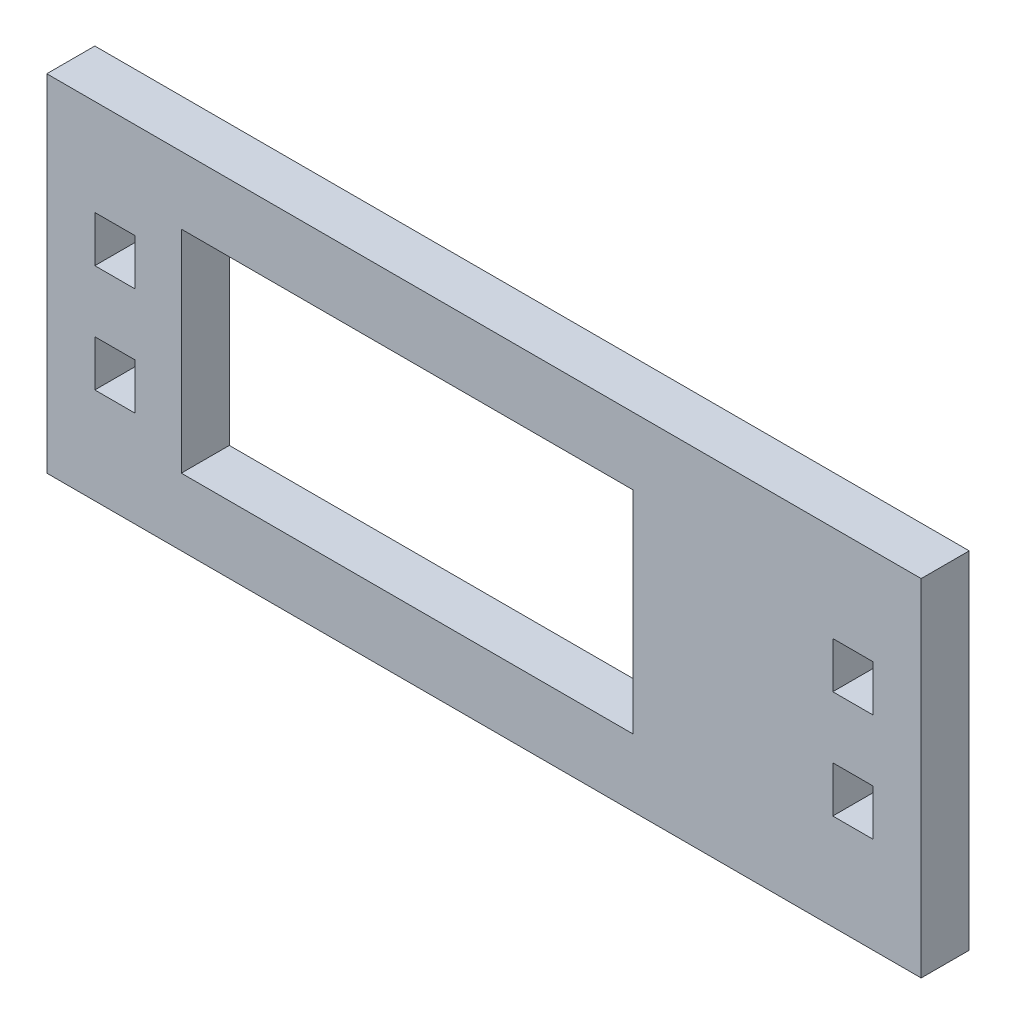
from build123d import *

# Parameters (mm, degrees)
SKETCH1_W           = 115.57
SKETCH1_H           = 45.72
BOSS_EXTRUDE1_DEPTH = 6.35
SKETCH2_W           = 59.69
SKETCH2_H           = 27.94
CUT_EXTRUDE1_DEPTH  = 7.35
SKETCH3_W           = 5.334
SKETCH3_H           = 6.096
CUT_EXTRUDE2_DEPTH  = 7.35


with BuildPart() as part:
    # Sketch1 → Boss-Extrude1 (new body)
    with BuildSketch(Plane.XY):
        Rectangle(SKETCH1_W, SKETCH1_H)
    extrude(amount=BOSS_EXTRUDE1_DEPTH)

    # Sketch2 → Cut-Extrude1 (cut, through all)
    with BuildSketch(Plane.XY.offset(6.35)):
        with Locations((-10.16, 0)):
            Rectangle(SKETCH2_W, SKETCH2_H)
    extrude(amount=-CUT_EXTRUDE1_DEPTH, mode=Mode.SUBTRACT)

    # Sketch3 → Cut-Extrude2 (cut, through all)
    with BuildSketch(Plane.XY.offset(6.35)):
        with Locations((-48.768, 7.112)):
            Rectangle(SKETCH3_W, SKETCH3_H)
        with Locations((-48.768, -7.112)):
            Rectangle(SKETCH3_W, SKETCH3_H)
        with Locations((48.768, -7.112)):
            Rectangle(SKETCH3_W, SKETCH3_H)
        with Locations((48.768, 7.112)):
            Rectangle(SKETCH3_W, SKETCH3_H)
    extrude(amount=-CUT_EXTRUDE2_DEPTH, mode=Mode.SUBTRACT)


solid = part.part
